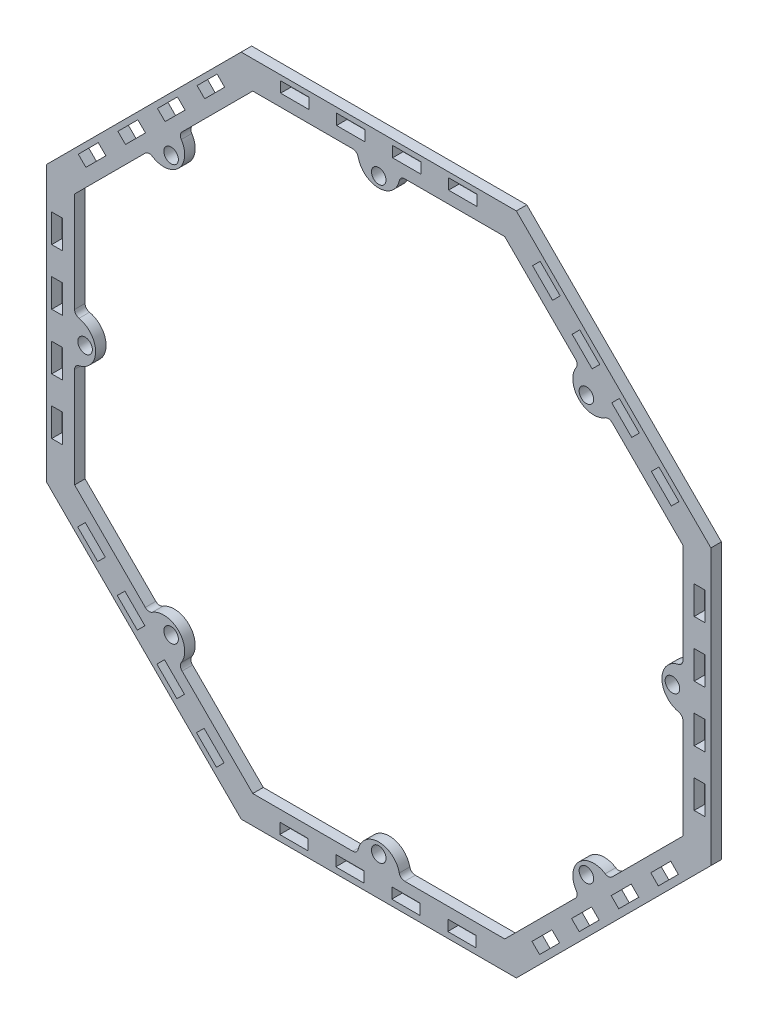
from build123d import *

# Parameters (mm, degrees)
BOSS_EXTRUDE1_DEPTH = 4.7625
SKETCH2_R           = 3.302
BOSS_EXTRUDE2_DEPTH = 4.7625
SKETCH3_W           = 12.827
SKETCH3_H           = 4.8768
SKETCH3_W_2         = 4.8768
SKETCH3_H_2         = 12.827
PANEL_SLOTS_DEPTH   = 5.7625
FILLET2_R           = 2.54


with BuildPart() as part:
    # Sketch1 → Boss-Extrude1 (new body)
    with BuildSketch(Plane.XY):
        Polygon((-150.669615327, -62.417005507), (-62.404018861, -150.674994572), (62.417005507, -150.669615327), (150.674994572, -62.404018861), (150.669615327, 62.417005507), (62.404018861, 150.674994572), (-62.417005507, 150.669615327), (-150.674994572, 62.404018861), align=None)
        Polygon((-137.969842044, -57.155945955), (-57.144053939, -137.974767879), (57.155945955, -137.969842044), (137.974767879, -57.144053939), (137.969842044, 57.155945955), (57.144053939, 137.974767879), (-57.155945955, 137.969842044), (-137.974767879, 57.144053939), align=None, mode=Mode.SUBTRACT)
    extrude(amount=BOSS_EXTRUDE1_DEPTH)

    # Sketch2 → Boss-Extrude2 (add)
    with BuildSketch(Plane.XY.offset(4.7625)):
        with BuildLine():
            Line((-104.300258744, 90.821465649), (-90.83045509, 104.292430334))
            ThreePointArc((-90.83045509, 104.292430334), (-90.829874575, 90.822046164), (-104.300258744, 90.821465649))
        make_face()
        with Locations((-94.197615746, 94.189497078)):
            Circle(SKETCH2_R, mode=Mode.SUBTRACT)
        with BuildLine():
            Line((104.292430334, 90.83045509), (90.821465649, 104.300258744))
            ThreePointArc((90.821465649, 104.300258744), (90.822046164, 90.829874575), (104.292430334, 90.83045509))
        make_face()
        with Locations((94.189497078, 94.197615746)):
            Circle(SKETCH2_R, mode=Mode.SUBTRACT)
        with BuildLine():
            Line((104.300258744, -90.821465649), (90.83045509, -104.292430334))
            ThreePointArc((90.83045509, -104.292430334), (90.829874575, -90.822046164), (104.300258744, -90.821465649))
        make_face()
        with Locations((94.197615746, -94.189497078)):
            Circle(SKETCH2_R, mode=Mode.SUBTRACT)
        with BuildLine():
            Line((-104.292430334, -90.83045509), (-90.821465649, -104.300258744))
            ThreePointArc((-90.821465649, -104.300258744), (-90.822046164, -90.829874575), (-104.292430334, -90.83045509))
        make_face()
        with Locations((-94.189497078, -94.197615746)):
            Circle(SKETCH2_R, mode=Mode.SUBTRACT)
        with BuildLine():
            Line((-137.972715448, 9.519053983), (-137.971894475, -9.530945999))
            ThreePointArc((-137.971894475, -9.530945999), (-128.44730497, -0.005535522), (-137.972715448, 9.519053983))
        make_face()
        with Locations((-133.209804966, -0.005740765)):
            Circle(SKETCH2_R, mode=Mode.SUBTRACT)
        with BuildLine():
            Line((137.971894475, 9.530945999), (137.972715448, -9.519053983))
            ThreePointArc((137.972715448, -9.519053983), (128.44730497, 0.005535522), (137.971894475, 9.530945999))
        make_face()
        with Locations((133.209804966, 0.005740765)):
            Circle(SKETCH2_R, mode=Mode.SUBTRACT)
        with BuildLine():
            Line((-9.530945999, 137.971894475), (9.519053983, 137.972715448))
            ThreePointArc((9.519053983, 137.972715448), (-0.005535522, 128.44730497), (-9.530945999, 137.971894475))
        make_face()
        with Locations((-0.005740748, 133.209394475)):
            Circle(SKETCH2_R, mode=Mode.SUBTRACT)
        with BuildLine():
            Line((-9.519053983, -137.972715448), (9.530945999, -137.971894475))
            ThreePointArc((9.530945999, -137.971894475), (0.005535522, -128.44730497), (-9.519053983, -137.972715448))
        make_face()
        with Locations((0.005740748, -133.209394475)):
            Circle(SKETCH2_R, mode=Mode.SUBTRACT)
    extrude(amount=-BOSS_EXTRUDE2_DEPTH)

    # Sketch3 → Panel Slots (cut, through all)
    with BuildSketch(Plane.XY.offset(4.7625)):
        with Locations((-38.105945973, 145.908163017)):
            Rectangle(SKETCH3_W, SKETCH3_H)
        Polygon((96.805468004, 105.817611483), (87.735409322, 114.887670166), (91.183827673, 118.336088516), (100.253886355, 109.266029834), align=None)
        with Locations((12.69405398, 145.910352276)):
            Rectangle(SKETCH3_W, SKETCH3_H)
        Polygon((136.176458846, 73.346553423), (127.106400164, 82.416612106), (123.657981813, 78.968193755), (132.728040496, 69.898135073), align=None)
        Polygon((82.292600109, 127.225768039), (73.222541427, 136.295826721), (69.774123076, 132.847408371), (78.844181759, 123.777349689), align=None)
        Polygon((114.76675425, 87.857873278), (105.696695568, 96.92793196), (109.145113918, 100.376350311), (118.215172601, 91.306291629), align=None)
        with Locations((145.520236425, 12.705011671)):
            Rectangle(SKETCH3_W_2, SKETCH3_H_2)
        with Locations((145.522425685, -38.094988281)):
            Rectangle(SKETCH3_W_2, SKETCH3_H_2)
        with Locations((145.519141795, 38.105011648)):
            Rectangle(SKETCH3_W_2, SKETCH3_H_2)
        with Locations((145.521331055, -12.694988305)):
            Rectangle(SKETCH3_W_2, SKETCH3_H_2)
        Polygon((105.428590262, -96.806402329), (114.498648944, -87.736343647), (117.947067295, -91.184761998), (108.877008612, -100.25482068), align=None)
        Polygon((72.957532202, -136.177393171), (82.027590884, -127.107334489), (78.579172534, -123.658916139), (69.509113851, -132.728974821), align=None)
        Polygon((126.836746817, -82.293534434), (135.9068055, -73.223475752), (132.458387149, -69.775057401), (123.388328467, -78.845116084), align=None)
        Polygon((87.468852057, -114.767688575), (96.538910739, -105.697629893), (99.987329089, -109.146048243), (90.917270407, -118.216106926), align=None)
        with Locations((12.31599045, -145.52117075)):
            Rectangle(SKETCH3_W, SKETCH3_H)
        with Locations((-38.484009503, -145.52336001)):
            Rectangle(SKETCH3_W, SKETCH3_H)
        with Locations((37.715990426, -145.52007612)):
            Rectangle(SKETCH3_W, SKETCH3_H)
        with Locations((38.094053956, 145.911446906)):
            Rectangle(SKETCH3_W, SKETCH3_H)
        with Locations((-12.705945997, 145.909257647)):
            Rectangle(SKETCH3_W, SKETCH3_H)
        with Locations((-13.084009527, -145.52226538)):
            Rectangle(SKETCH3_W, SKETCH3_H)
        Polygon((-97.195423551, -105.429524587), (-88.125364869, -114.499583269), (-91.573783219, -117.94800162), (-100.643841902, -108.877942937), align=None)
        Polygon((-136.566414393, -72.958466527), (-127.496355711, -82.028525209), (-124.04793736, -78.580106859), (-133.117996042, -69.510048176), align=None)
        Polygon((-82.682555656, -126.837681143), (-73.612496974, -135.907739825), (-70.164078623, -132.459321474), (-79.234137305, -123.389262792), align=None)
        Polygon((-115.156709797, -87.469786382), (-106.086651114, -96.539845064), (-109.535069465, -99.988263414), (-118.605128147, -90.918204732), align=None)
        with Locations((-145.910191972, -12.316924775)):
            Rectangle(SKETCH3_W_2, SKETCH3_H_2)
        with Locations((-145.912381231, 38.483075178)):
            Rectangle(SKETCH3_W_2, SKETCH3_H_2)
        with Locations((-145.909097342, -37.716924751)):
            Rectangle(SKETCH3_W_2, SKETCH3_H_2)
        with Locations((-145.911286602, 13.083075201)):
            Rectangle(SKETCH3_W_2, SKETCH3_H_2)
        Polygon((-105.818545808, 97.194489226), (-114.888604491, 88.124430544), (-118.337022841, 91.572848894), (-109.266964159, 100.642907576), align=None)
        Polygon((-73.347487748, 136.565480068), (-82.417546431, 127.495421386), (-78.96912808, 124.047003035), (-69.899069398, 133.117061717), align=None)
        Polygon((-127.226702364, 82.681621331), (-136.296761046, 73.611562649), (-132.848342696, 70.163144298), (-123.778284014, 79.23320298), align=None)
        Polygon((-87.858807603, 115.155775472), (-96.928866285, 106.085716789), (-100.377284636, 109.53413514), (-91.307225954, 118.604193822), align=None)
    extrude(amount=-PANEL_SLOTS_DEPTH, mode=Mode.SUBTRACT)

    # Fillet2
    fillet2_edges = [part.edges().sort_by_distance(p)[0] for p in [
        (9.519053983, 137.972715448, 2.38125),
        (-9.530945999, 137.971894475, 2.38125),
        (-9.519053983, -137.972715448, 2.38125),
        (9.530945999, -137.971894475, 2.38125),
        (-90.83045509, 104.292430334, 2.38125),
        (-104.300258744, 90.821465649, 2.38125),
        (104.292430334, 90.83045509, 2.38125),
        (90.821465649, 104.300258744, 2.38125),
        (90.83045509, -104.292430334, 2.38125),
        (104.300258744, -90.821465649, 2.38125),
        (-104.292430334, -90.83045509, 2.38125),
        (-90.821465649, -104.300258744, 2.38125),
        (-137.972715448, 9.519053983, 2.38125),
        (-137.971894475, -9.530945999, 2.38125),
        (137.972715448, -9.519053983, 2.38125),
        (137.971894475, 9.530945999, 2.38125),
    ]]
    fillet(fillet2_edges, radius=FILLET2_R)


solid = part.part
